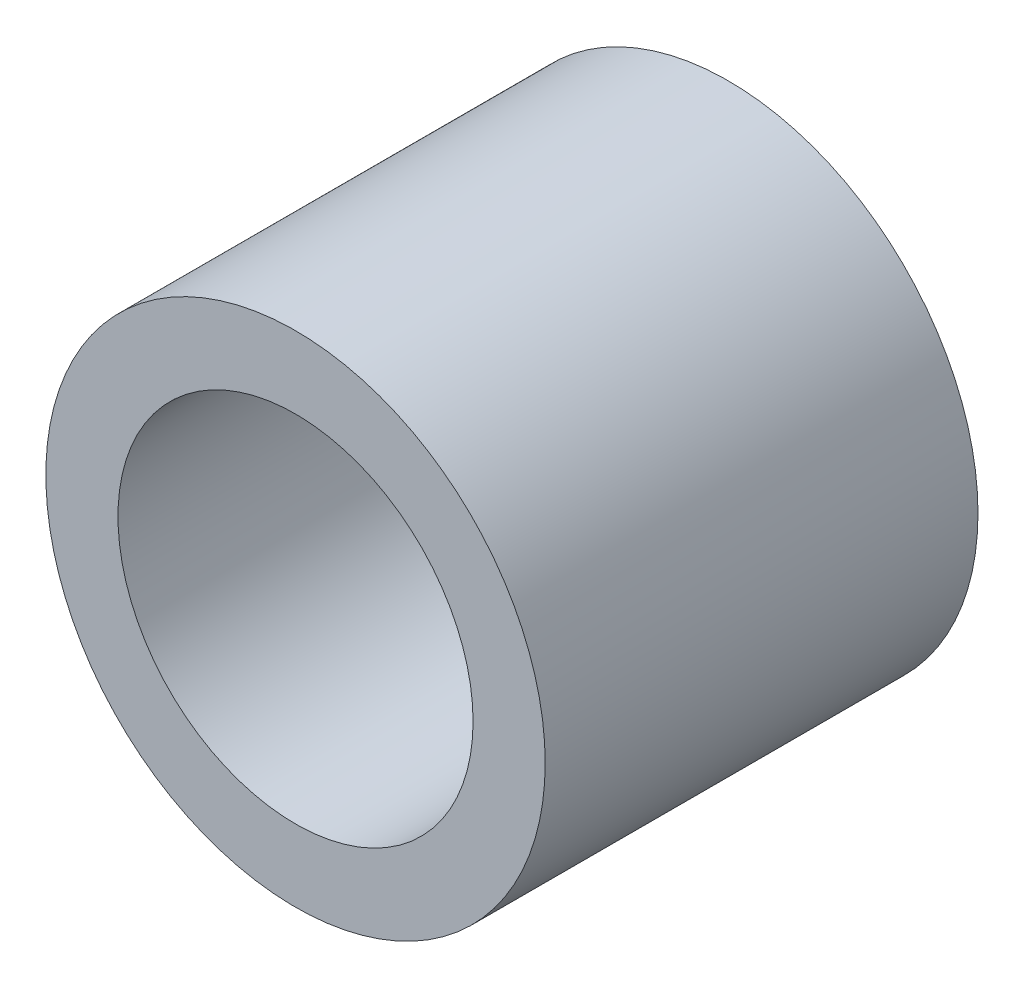
from build123d import *

# Parameters (mm, degrees)
SKETCH1_R           = 22.5
SKETCH1_R_2         = 16
BOSS_EXTRUDE1_DEPTH = 39


with BuildPart() as part:
    # Sketch1 → Boss-Extrude1 (new body)
    with BuildSketch(Plane.XY):
        Circle(SKETCH1_R)
        Circle(SKETCH1_R_2, mode=Mode.SUBTRACT)
    extrude(amount=BOSS_EXTRUDE1_DEPTH)


solid = part.part
